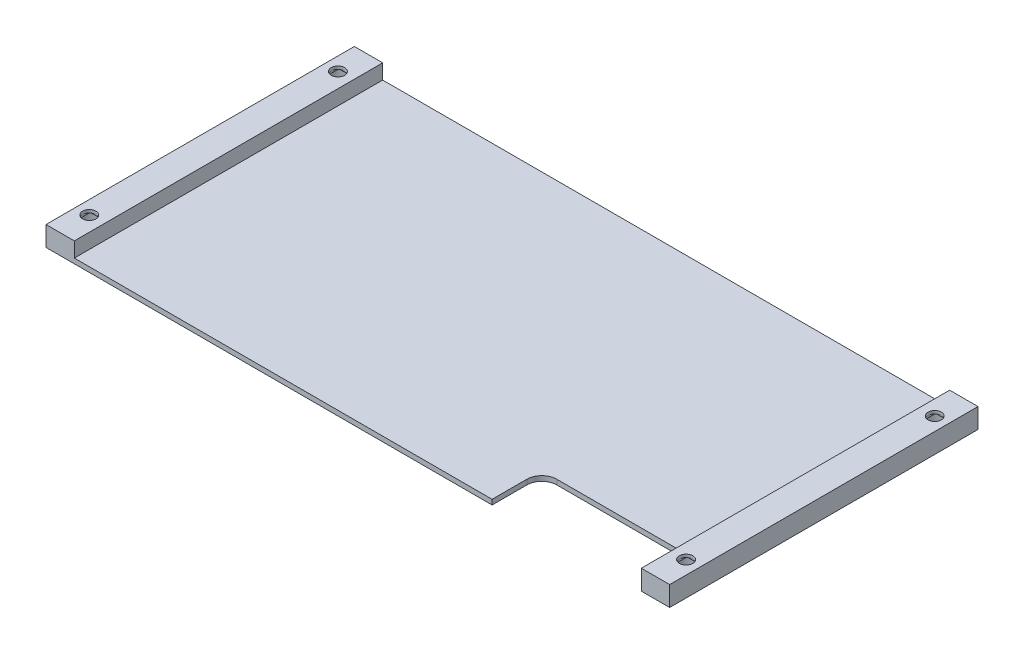
from build123d import *

# Parameters (mm, degrees)
SKETCH1_W           = 126
SKETCH1_H           = 62
BOSS_EXTRUDE1_DEPTH = 1
SKETCH2_W           = 6
SKETCH2_H           = 62
BOSS_EXTRUDE2_DEPTH = 3
SKETCH3_R           = 1.35
CUT_EXTRUDE1_DEPTH  = 5
SKETCH4_R           = 2.5
CUT_EXTRUDE2_DEPTH  = 3
SKETCH5_W           = 30
SKETCH5_H           = 10
CUT_EXTRUDE3_DEPTH  = 5
FILLET1_R           = 3
CUT_EXTRUDE4_DEPTH  = 0.2
SKETCH7_W           = 2.7
SKETCH7_H           = 2.7
CUT_EXTRUDE5_DEPTH  = 0.2
SKETCH8_W           = 0.3
SKETCH8_H           = 62
CUT_EXTRUDE6_DEPTH  = 5


with BuildPart() as part:
    # Sketch1 → Boss-Extrude1 (new body)
    with BuildSketch(Plane(origin=(0, 0, 0), x_dir=(1, 0, 0), z_dir=(0, 1, 0))):
        Rectangle(SKETCH1_W, SKETCH1_H)
    extrude(amount=BOSS_EXTRUDE1_DEPTH)

    # Sketch2 → Boss-Extrude2 (add)
    with BuildSketch(Plane(origin=(0, 1, 0), x_dir=(1, 0, 0), z_dir=(0, 1, 0))):
        with Locations((-60, 0)):
            Rectangle(SKETCH2_W, SKETCH2_H)
        with Locations((60, 0)):
            Rectangle(SKETCH2_W, SKETCH2_H)
    extrude(amount=BOSS_EXTRUDE2_DEPTH)

    # Sketch3 → Cut-Extrude1 (cut, through all)
    with BuildSketch(Plane(origin=(0, 4, 0), x_dir=(1, 0, 0), z_dir=(0, 1, 0))):
        with Locations((-60, 25)):
            Circle(SKETCH3_R)
        with Locations((-60, -25)):
            Circle(SKETCH3_R)
        with Locations((60, -25)):
            Circle(SKETCH3_R)
        with Locations((60, 25)):
            Circle(SKETCH3_R)
    extrude(amount=-CUT_EXTRUDE1_DEPTH, mode=Mode.SUBTRACT)

    # Sketch4 → Cut-Extrude2 (cut)
    with BuildSketch(Plane.XZ):
        with Locations((60, -25)):
            Circle(SKETCH4_R)
        with Locations((60, 25)):
            Circle(SKETCH4_R)
        with Locations((-60, 25)):
            Circle(SKETCH4_R)
        with Locations((-60, -25)):
            Circle(SKETCH4_R)
    extrude(amount=-CUT_EXTRUDE2_DEPTH, mode=Mode.SUBTRACT)

    # Sketch5 → Cut-Extrude3 (cut, through all)
    with BuildSketch(Plane.XZ):
        with Locations((42, 26)):
            Rectangle(SKETCH5_W, SKETCH5_H)
    extrude(amount=-CUT_EXTRUDE3_DEPTH, mode=Mode.SUBTRACT)

    # Fillet1
    fillet1_edges = [part.edges().sort_by_distance(p)[0] for p in [
        (27, 0.5, 21),
        (57, 0.5, 21),
    ]]
    fillet(fillet1_edges, radius=FILLET1_R)

    # Sketch6 → Cut-Extrude4 (cut)
    with BuildSketch(Plane.XZ.offset(-3)):
        with BuildLine():
            Line((-61.35, 22.895837459), (-61.35, 27.104162541))
            ThreePointArc((-61.35, 27.104162541), (-60, 27.5), (-58.65, 27.104162541))
            Line((-58.65, 27.104162541), (-58.65, 22.895837459))
            ThreePointArc((-58.65, 22.895837459), (-60, 22.5), (-61.35, 22.895837459))
        make_face()
        with BuildLine():
            Line((-61.35, -27.104162541), (-61.35, -22.895837459))
            ThreePointArc((-61.35, -22.895837459), (-60, -22.5), (-58.65, -22.895837459))
            Line((-58.65, -22.895837459), (-58.65, -27.104162541))
            ThreePointArc((-58.65, -27.104162541), (-60, -27.5), (-61.35, -27.104162541))
        make_face()
    cut_extrude4 = extrude(amount=-CUT_EXTRUDE4_DEPTH, mode=Mode.SUBTRACT)

    # Sketch7 → Cut-Extrude5 (cut)
    with BuildSketch(Plane.XZ.offset(-3.2)):
        with Locations((-60, -25)):
            Rectangle(SKETCH7_W, SKETCH7_H)
        with Locations((-60, 25)):
            Rectangle(SKETCH7_W, SKETCH7_H)
    cut_extrude5 = extrude(amount=-CUT_EXTRUDE5_DEPTH, mode=Mode.SUBTRACT)

    # Mirror1: Cut-Extrude4, Cut-Extrude5 across plane
    add(cut_extrude4.mirror(Plane(origin=(0, 0, 0), x_dir=(0, 0, 1), z_dir=(1, 0, 0))), mode=Mode.SUBTRACT)
    add(cut_extrude5.mirror(Plane(origin=(0, 0, 0), x_dir=(0, 0, 1), z_dir=(1, 0, 0))), mode=Mode.SUBTRACT)

    # Sketch8 → Cut-Extrude6 (cut, through all)
    with BuildSketch(Plane(origin=(0, 4, 0), x_dir=(1, 0, 0), z_dir=(0, 1, 0))):
        with Locations((-62.85, 0)):
            Rectangle(SKETCH8_W, SKETCH8_H)
        with Locations((62.85, 0)):
            Rectangle(SKETCH8_W, SKETCH8_H)
    extrude(amount=-CUT_EXTRUDE6_DEPTH, mode=Mode.SUBTRACT)


solid = part.part
